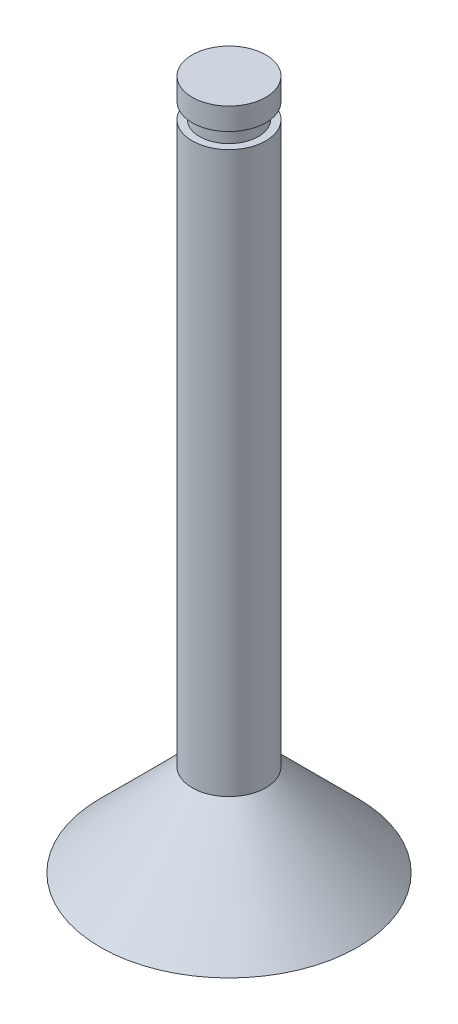
from build123d import *


with BuildPart() as part:
    # Skica1 → Rotovat1 (revolve)
    with BuildSketch(Plane.XY):
        Polygon((0, 0), (7, 0), (2, 5), (2, 35.45), (1.6, 35.45), (1.6, 36.3), (2, 36.3), (2, 37.5), (0, 37.5), align=None)
    revolve(axis=Axis((0, 39.732142857, 0), (0, -1, 0)))


solid = part.part
